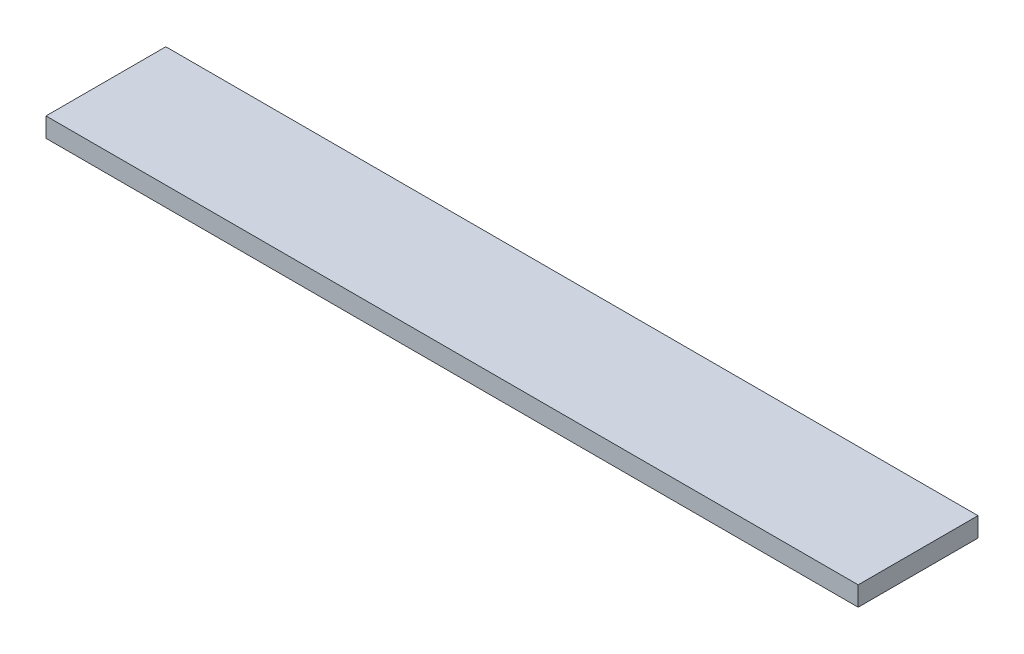
from build123d import *

# Parameters (mm, degrees)
SKETCH1_W           = 61
SKETCH1_H           = 9
BOSS_EXTRUDE1_DEPTH = 1.46


with BuildPart() as part:
    # Sketch1 → Boss-Extrude1 (new body)
    with BuildSketch(Plane(origin=(0, 0, 0), x_dir=(1, 0, 0), z_dir=(0, 1, 0))):
        Rectangle(SKETCH1_W, SKETCH1_H)
    extrude(amount=BOSS_EXTRUDE1_DEPTH)


solid = part.part
